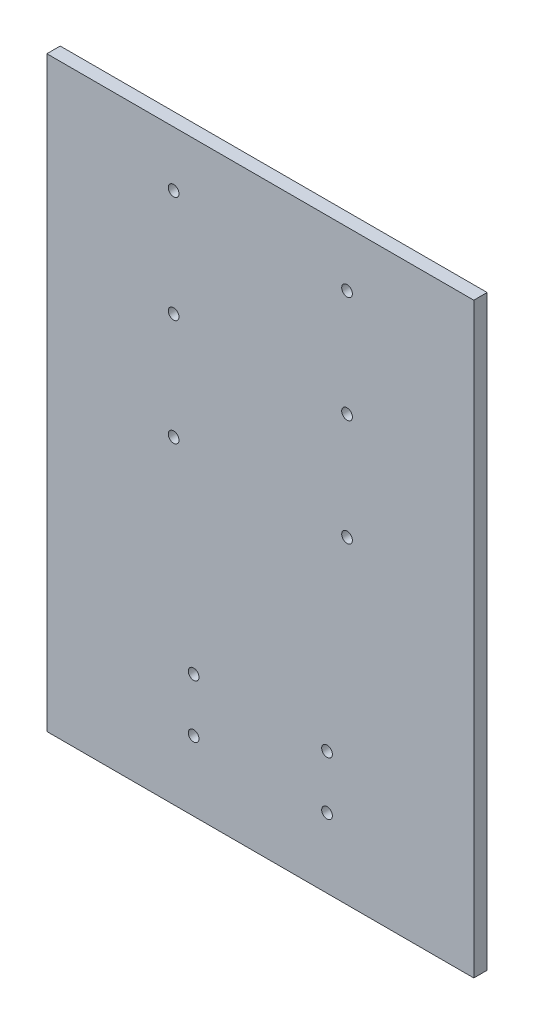
from build123d import *

# Parameters (mm, degrees)
SKETCH1_W                   = 203.2
SKETCH1_H                   = 279.4
BOSS_EXTRUDE1_DEPTH         = 6.35
F_1_4_20_TAPPED_HOLE1_D     = 5.1054
F_1_4_20_TAPPED_HOLE1_DEPTH = 8.81126
F_1_4_20_TAPPED_HOLE1_TIP   = 1.533816902


with BuildPart() as part:
    # Sketch1 → Boss-Extrude1 (new body)
    with BuildSketch(Plane.XY):
        with Locations((101.6, 139.7)):
            Rectangle(SKETCH1_W, SKETCH1_H)
    extrude(amount=BOSS_EXTRUDE1_DEPTH)

    # 1/4-20 Tapped Hole1
    with Locations(Plane(origin=(0, 0, 0), x_dir=(-1, 0, 0), z_dir=(0, 0, -1))):
        with Locations((-60.325, 253.122878716), (-142.875, 253.122878716), (-142.875, 202.322878716), (-142.875, 151.522878716), (-60.325, 151.522878716), (-60.325, 202.322878716), (-133.349999974, 58.567878716), (-133.349999974, 33.167878716), (-69.849999974, 33.167878716), (-69.849999974, 58.567878716)):
            Hole(F_1_4_20_TAPPED_HOLE1_D / 2, depth=F_1_4_20_TAPPED_HOLE1_DEPTH)
            with Locations((0, 0, -(F_1_4_20_TAPPED_HOLE1_DEPTH + F_1_4_20_TAPPED_HOLE1_TIP / 2))):  # 118° drill point
                Cone(0, F_1_4_20_TAPPED_HOLE1_D / 2, F_1_4_20_TAPPED_HOLE1_TIP, mode=Mode.SUBTRACT)


solid = part.part
